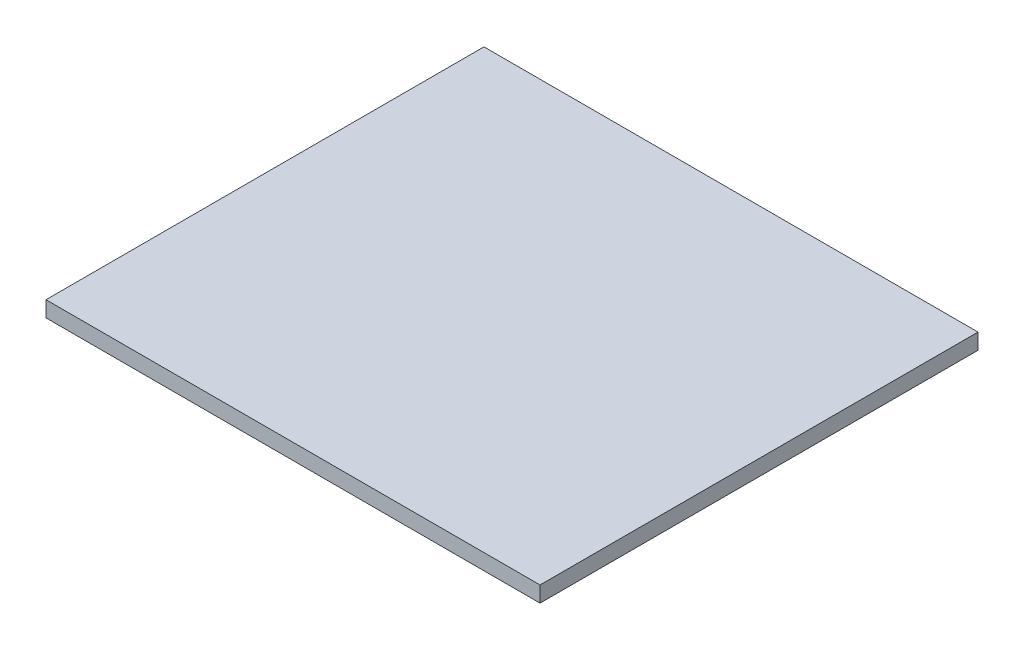
from build123d import *

# Parameters (mm, degrees)
SKETCH_1_W      = 564
SKETCH_1_H      = 500
EXTRUDE_1_DEPTH = 18


with BuildPart() as part:
    # Эскиз1 → Бобышка-Вытянуть1 (new body)
    with BuildSketch(Plane(origin=(0, 0, 0), x_dir=(1, 0, 0), z_dir=(0, 1, 0))):
        Rectangle(SKETCH_1_W, SKETCH_1_H)
    extrude(amount=EXTRUDE_1_DEPTH)


solid = part.part
